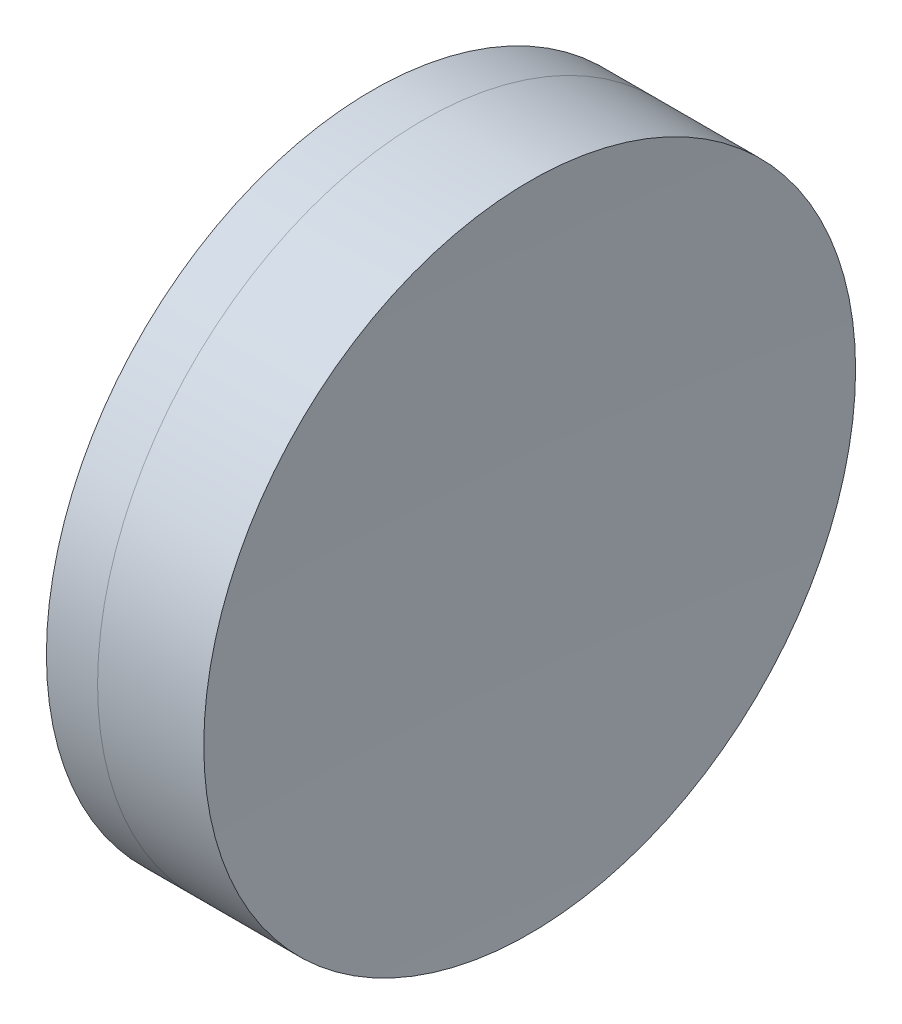
from build123d import *


with BuildPart() as part:
    # 草图1 one side → 旋转1 (revolve)
    with BuildSketch(Plane(origin=(0, 0, 0), x_dir=(1, 0, 0), z_dir=(0, 1, 0)), mode=Mode.PRIVATE) as revolve_1_sk:
        with BuildLine():
            ThreePointArc((95.825870489, 12.7), (94.955192063, 6.376511056), (94.664159254, 0))
            Line((94.664159254, 0), (98.664159254, 0))
            ThreePointArc((98.664159254, 0), (98.45285345, 6.364016611), (97.819866833, 12.7))
            Line((97.819866833, 12.7), (95.825870489, 12.7))
        make_face()
    revolve(revolve_1_sk.sketch.rotate(Axis((-0.816062176, 0, 0), (1, 0, 0)), 180), axis=Axis((-0.816062176, 0, 0), (1, 0, 0)))  # turned: the seam where the file's is


with BuildPart() as body_2:
    # 草图2 one side → 旋转2 (revolve)
    with BuildSketch(Plane(origin=(0, 0, 0), x_dir=(1, 0, 0), z_dir=(0, 1, 0)), mode=Mode.PRIVATE) as revolve_2_sk:
        with BuildLine():
            Line((101.958309165, 12.7), (97.819866833, 12.7))
            ThreePointArc((97.819866833, 12.7), (98.45285345, 6.364016611), (98.664159254, 0))
            Line((98.664159254, 0), (101.664159254, 0))
            ThreePointArc((101.664159254, 0), (101.737706591, 6.351703003), (101.958309165, 12.7))
        make_face()
    revolve(revolve_2_sk.sketch.rotate(Axis((-0.551919993, 0, 0), (1, 0, 0)), 180), axis=Axis((-0.551919993, 0, 0), (1, 0, 0)))  # turned: the seam where the file's is


solid = Compound([part.part, body_2.part])
